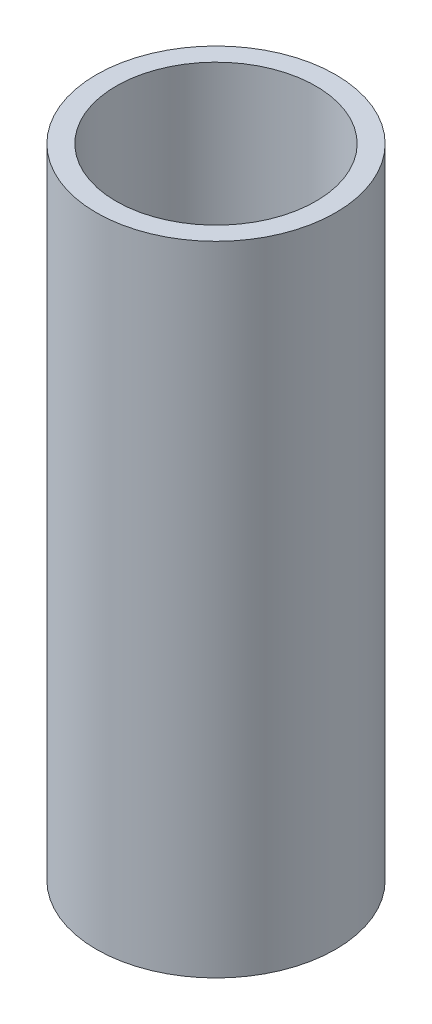
from build123d import *

# Parameters (mm, degrees)
SKETCH1_R           = 9.525
SKETCH1_R_2         = 7.9502
BOSS_EXTRUDE1_DEPTH = 50.8


with BuildPart() as part:
    # Sketch1 → Boss-Extrude1 (new body)
    with BuildSketch(Plane(origin=(0, 0, 0), x_dir=(1, 0, 0), z_dir=(0, 1, 0))):
        Circle(SKETCH1_R)
        Circle(SKETCH1_R_2, mode=Mode.SUBTRACT)
    extrude(amount=BOSS_EXTRUDE1_DEPTH)


solid = part.part
